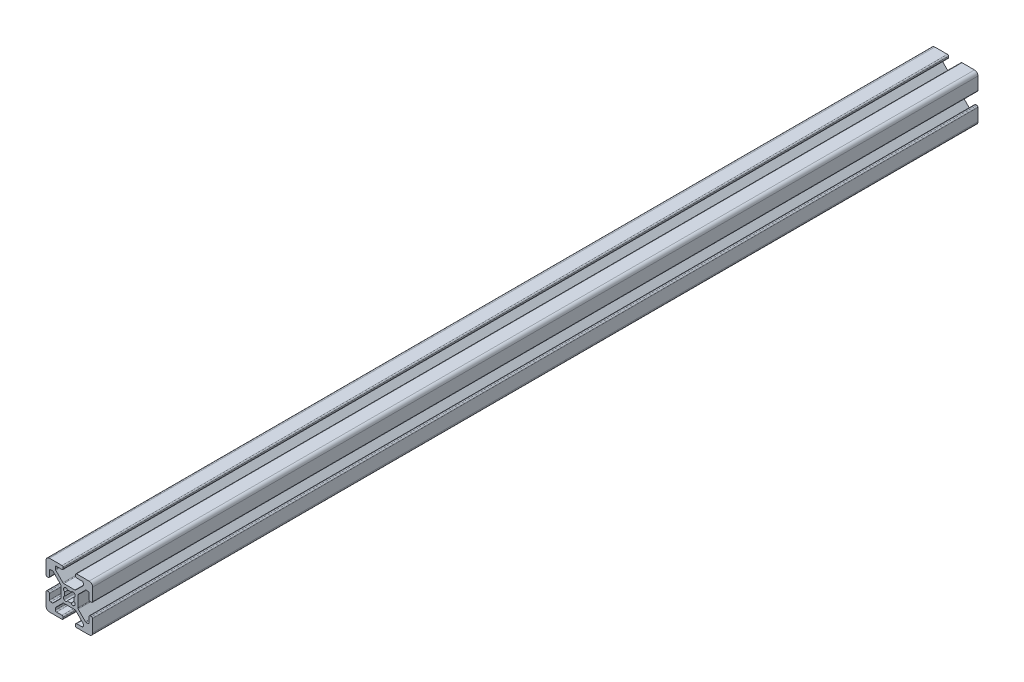
from build123d import *

# Parameters (mm, degrees)
EXTRUDE1_DEPTH = 380


with BuildPart() as part:
    # Sketch1 → Extrude1 (new body)
    with BuildSketch(Plane.XY):
        with BuildLine():
            Line((-5.032287798, -0.341059771), (-5.516287798, -0.341059771))
            ThreePointArc((-5.516287798, -0.341059771), (-5.875498042, -0.192270016), (-6.024287798, 0.166940229))
            Line((-6.024287798, 0.166940229), (-6.024287798, 2.515940229))
            ThreePointArc((-6.024287798, 2.515940229), (-6.173077553, 2.875150474), (-6.532287798, 3.023940229))
            Line((-6.532287798, 3.023940229), (-7.258207136, 3.023940229))
            ThreePointArc((-7.258207136, 3.023940229), (-7.45261032, 2.985271032), (-7.617417381, 2.875150474))
            Line((-7.617417381, 2.875150474), (-10.720498042, -0.227930187))
            ThreePointArc((-10.720498042, -0.227930187), (-10.8306186, -0.392737249), (-10.869287798, -0.587140432))
            Line((-10.869287798, -0.587140432), (-10.869287798, -5.354979109))
            ThreePointArc((-10.869287798, -5.354979109), (-10.8306186, -5.549382293), (-10.720498042, -5.714189354))
            Line((-10.720498042, -5.714189354), (-7.617417381, -8.817270016))
            ThreePointArc((-7.617417381, -8.817270016), (-7.45261032, -8.927390573), (-7.258207136, -8.966059771))
            Line((-7.258207136, -8.966059771), (-6.532287798, -8.966059771))
            ThreePointArc((-6.532287798, -8.966059771), (-6.173077553, -8.817270016), (-6.024287798, -8.458059771))
            Line((-6.024287798, -8.458059771), (-6.024287798, -6.109059771))
            ThreePointArc((-6.024287798, -6.109059771), (-5.875498042, -5.749849526), (-5.516287798, -5.601059771))
            Line((-5.516287798, -5.601059771), (-5.032287798, -5.601059771))
            ThreePointArc((-5.032287798, -5.601059771), (-4.673077553, -5.749849526), (-4.524287798, -6.109059771))
            Line((-4.524287798, -6.109059771), (-4.524287798, -11.471059771))
            ThreePointArc((-4.524287798, -11.471059771), (-4.963627626, -12.531719943), (-6.024287798, -12.971059771))
            Line((-6.024287798, -12.971059771), (-11.386287798, -12.971059771))
            ThreePointArc((-11.386287798, -12.971059771), (-11.745498042, -12.822270016), (-11.894287798, -12.463059771))
            Line((-11.894287798, -12.463059771), (-11.894287798, -11.979059771))
            ThreePointArc((-11.894287798, -11.979059771), (-11.745498042, -11.619849526), (-11.386287798, -11.471059771))
            Line((-11.386287798, -11.471059771), (-9.037287798, -11.471059771))
            ThreePointArc((-9.037287798, -11.471059771), (-8.678077553, -11.322270016), (-8.529287798, -10.963059771))
            Line((-8.529287798, -10.963059771), (-8.529287798, -10.237140432))
            ThreePointArc((-8.529287798, -10.237140432), (-8.567956995, -10.042737249), (-8.678077553, -9.877930187))
            Line((-8.678077553, -9.877930187), (-11.781158214, -6.774849526))
            ThreePointArc((-11.781158214, -6.774849526), (-11.945965275, -6.664728968), (-12.140368459, -6.626059771))
            Line((-12.140368459, -6.626059771), (-16.908207136, -6.626059771))
            ThreePointArc((-16.908207136, -6.626059771), (-17.10261032, -6.664728968), (-17.267417381, -6.774849526))
            Line((-17.267417381, -6.774849526), (-20.370498042, -9.877930187))
            ThreePointArc((-20.370498042, -9.877930187), (-20.4806186, -10.042737249), (-20.519287798, -10.237140432))
            Line((-20.519287798, -10.237140432), (-20.519287798, -10.963059771))
            ThreePointArc((-20.519287798, -10.963059771), (-20.370498042, -11.322270016), (-20.011287798, -11.471059771))
            Line((-20.011287798, -11.471059771), (-17.662287798, -11.471059771))
            ThreePointArc((-17.662287798, -11.471059771), (-17.303077553, -11.619849526), (-17.154287798, -11.979059771))
            Line((-17.154287798, -11.979059771), (-17.154287798, -12.463059771))
            ThreePointArc((-17.154287798, -12.463059771), (-17.303077553, -12.822270016), (-17.662287798, -12.971059771))
            Line((-17.662287798, -12.971059771), (-23.024287798, -12.971059771))
            ThreePointArc((-23.024287798, -12.971059771), (-24.084947969, -12.531719943), (-24.524287798, -11.471059771))
            Line((-24.524287798, -11.471059771), (-24.524287798, -6.109059771))
            ThreePointArc((-24.524287798, -6.109059771), (-24.375498042, -5.749849526), (-24.016287798, -5.601059771))
            Line((-24.016287798, -5.601059771), (-23.532287798, -5.601059771))
            ThreePointArc((-23.532287798, -5.601059771), (-23.173077553, -5.749849526), (-23.024287798, -6.109059771))
            Line((-23.024287798, -6.109059771), (-23.024287798, -8.458059771))
            ThreePointArc((-23.024287798, -8.458059771), (-22.875498042, -8.817270016), (-22.516287798, -8.966059771))
            Line((-22.516287798, -8.966059771), (-21.790368459, -8.966059771))
            ThreePointArc((-21.790368459, -8.966059771), (-21.595965275, -8.927390573), (-21.431158214, -8.817270016))
            Line((-21.431158214, -8.817270016), (-18.328077553, -5.714189354))
            ThreePointArc((-18.328077553, -5.714189354), (-18.217956995, -5.549382293), (-18.179287798, -5.354979109))
            Line((-18.179287798, -5.354979109), (-18.179287798, -0.587140432))
            ThreePointArc((-18.179287798, -0.587140432), (-18.217956995, -0.392737249), (-18.328077553, -0.227930187))
            Line((-18.328077553, -0.227930187), (-21.431158214, 2.875150474))
            ThreePointArc((-21.431158214, 2.875150474), (-21.595965275, 2.985271032), (-21.790368459, 3.023940229))
            Line((-21.790368459, 3.023940229), (-22.516287798, 3.023940229))
            ThreePointArc((-22.516287798, 3.023940229), (-22.875498042, 2.875150474), (-23.024287798, 2.515940229))
            Line((-23.024287798, 2.515940229), (-23.024287798, 0.166940229))
            ThreePointArc((-23.024287798, 0.166940229), (-23.173077553, -0.192270016), (-23.532287798, -0.341059771))
            Line((-23.532287798, -0.341059771), (-24.016287798, -0.341059771))
            ThreePointArc((-24.016287798, -0.341059771), (-24.375498042, -0.192270016), (-24.524287798, 0.166940229))
            Line((-24.524287798, 0.166940229), (-24.524287798, 5.528940229))
            ThreePointArc((-24.524287798, 5.528940229), (-24.084947969, 6.589600401), (-23.024287798, 7.028940229))
            Line((-23.024287798, 7.028940229), (-17.662287798, 7.028940229))
            ThreePointArc((-17.662287798, 7.028940229), (-17.303077553, 6.880150474), (-17.154287798, 6.520940229))
            Line((-17.154287798, 6.520940229), (-17.154287798, 6.036940229))
            ThreePointArc((-17.154287798, 6.036940229), (-17.303077553, 5.677729984), (-17.662287798, 5.528940229))
            Line((-17.662287798, 5.528940229), (-20.011287798, 5.528940229))
            ThreePointArc((-20.011287798, 5.528940229), (-20.370498042, 5.380150474), (-20.519287798, 5.020940229))
            Line((-20.519287798, 5.020940229), (-20.519287798, 4.295020891))
            ThreePointArc((-20.519287798, 4.295020891), (-20.4806186, 4.100617707), (-20.370498042, 3.935810646))
            Line((-20.370498042, 3.935810646), (-17.267417381, 0.832729984))
            ThreePointArc((-17.267417381, 0.832729984), (-17.10261032, 0.722609427), (-16.908207136, 0.683940229))
            Line((-16.908207136, 0.683940229), (-12.140368459, 0.683940229))
            ThreePointArc((-12.140368459, 0.683940229), (-11.945965275, 0.722609427), (-11.781158214, 0.832729984))
            Line((-11.781158214, 0.832729984), (-8.678077553, 3.935810646))
            ThreePointArc((-8.678077553, 3.935810646), (-8.567956995, 4.100617707), (-8.529287798, 4.295020891))
            Line((-8.529287798, 4.295020891), (-8.529287798, 5.020940229))
            ThreePointArc((-8.529287798, 5.020940229), (-8.678077553, 5.380150474), (-9.037287798, 5.528940229))
            Line((-9.037287798, 5.528940229), (-11.386287798, 5.528940229))
            ThreePointArc((-11.386287798, 5.528940229), (-11.745498042, 5.677729984), (-11.894287798, 6.036940229))
            Line((-11.894287798, 6.036940229), (-11.894287798, 6.520940229))
            ThreePointArc((-11.894287798, 6.520940229), (-11.745498042, 6.880150474), (-11.386287798, 7.028940229))
            Line((-11.386287798, 7.028940229), (-6.024287798, 7.028940229))
            ThreePointArc((-6.024287798, 7.028940229), (-4.963627626, 6.589600401), (-4.524287798, 5.528940229))
            Line((-4.524287798, 5.528940229), (-4.524287798, 0.166940229))
            ThreePointArc((-4.524287798, 0.166940229), (-4.673077553, -0.192270016), (-5.032287798, -0.341059771))
        make_face()
        with BuildLine():
            Line((-12.399386954, -5.275565737), (-12.219781831, -5.095960615))
            ThreePointArc((-12.219781831, -5.095960615), (-12.018349781, -4.327527582), (-12.589154291, -3.775036489))
            ThreePointArc((-12.589154291, -3.775036489), (-12.428787798, -2.971059771), (-12.589154291, -2.167083053))
            ThreePointArc((-12.589154291, -2.167083053), (-12.018349781, -1.61459196), (-12.219781831, -0.846158927))
            Line((-12.219781831, -0.846158927), (-12.399386954, -0.666553805))
            ThreePointArc((-12.399386954, -0.666553805), (-13.167819987, -0.465121754), (-13.72031108, -1.035926265))
            ThreePointArc((-13.72031108, -1.035926265), (-14.524287798, -0.875559771), (-15.328264516, -1.035926265))
            ThreePointArc((-15.328264516, -1.035926265), (-15.880755608, -0.465121754), (-16.649188641, -0.666553805))
            Line((-16.649188641, -0.666553805), (-16.828793764, -0.846158927))
            ThreePointArc((-16.828793764, -0.846158927), (-17.030225814, -1.61459196), (-16.459421304, -2.167083053))
            ThreePointArc((-16.459421304, -2.167083053), (-16.619787798, -2.971059771), (-16.459421304, -3.775036489))
            ThreePointArc((-16.459421304, -3.775036489), (-17.030225814, -4.327527582), (-16.828793764, -5.095960615))
            Line((-16.828793764, -5.095960615), (-16.649188641, -5.275565737))
            ThreePointArc((-16.649188641, -5.275565737), (-15.880755608, -5.476997788), (-15.328264516, -4.906193277))
            ThreePointArc((-15.328264516, -4.906193277), (-14.524287798, -5.066559771), (-13.72031108, -4.906193277))
            ThreePointArc((-13.72031108, -4.906193277), (-13.167819987, -5.476997788), (-12.399386954, -5.275565737))
        make_face(mode=Mode.SUBTRACT)
    extrude(amount=EXTRUDE1_DEPTH)


solid = part.part
